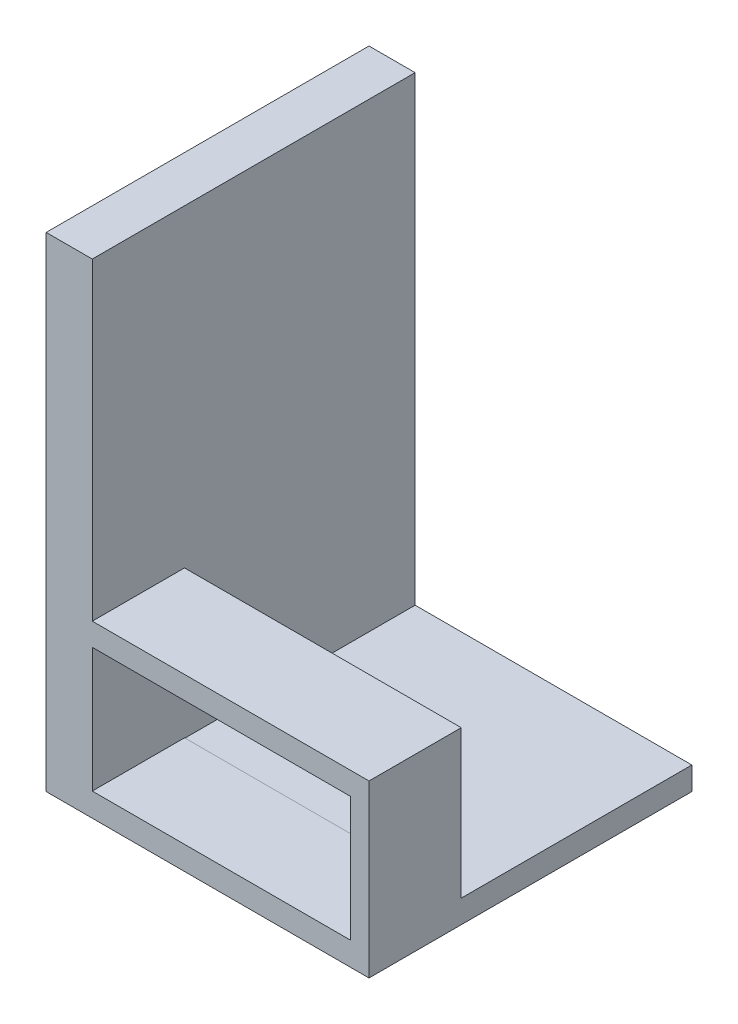
from build123d import *

# Parameters (mm, degrees)
SKETCH1_W           = 35
SKETCH1_H           = 35
BOSS_EXTRUDE1_DEPTH = 2.5
SKETCH2_W           = 5
SKETCH2_H           = 35
BOSS_EXTRUDE2_DEPTH = 50
SKETCH5_W           = 17
SKETCH5_H           = 35
CUT_EXTRUDE2_DEPTH  = 4
SKETCH6_W           = 30
SKETCH6_H           = 10
BOSS_EXTRUDE3_DEPTH = 16
SKETCH7_W           = 28
SKETCH7_H           = 13.5
CUT_EXTRUDE3_DEPTH  = 16


with BuildPart() as part:
    # Sketch1 → Boss-Extrude1 (new body)
    with BuildSketch(Plane(origin=(0, 0, 0), x_dir=(1, 0, 0), z_dir=(0, 1, 0))):
        with Locations((17.5, 17.5)):
            Rectangle(SKETCH1_W, SKETCH1_H)
    extrude(amount=BOSS_EXTRUDE1_DEPTH)

    # Sketch2 → Boss-Extrude2 (add)
    with BuildSketch(Plane(origin=(0, 2.5, 0), x_dir=(1, 0, 0), z_dir=(0, 1, 0))):
        with Locations((2.5, 17.5)):
            Rectangle(SKETCH2_W, SKETCH2_H)
    extrude(amount=BOSS_EXTRUDE2_DEPTH)

    # Sketch5 → Cut-Extrude2 (cut)
    with BuildSketch(Plane.ZY):
        with Locations((-17.553851225, 30)):
            Rectangle(SKETCH5_W, SKETCH5_H)
    extrude(amount=-CUT_EXTRUDE2_DEPTH, mode=Mode.SUBTRACT)

    # Sketch6 → Boss-Extrude3 (add)
    with BuildSketch(Plane(origin=(0, 2.5, 0), x_dir=(1, 0, 0), z_dir=(0, 1, 0))):
        with Locations((20, 5)):
            Rectangle(SKETCH6_W, SKETCH6_H)
    extrude(amount=BOSS_EXTRUDE3_DEPTH)

    # Sketch7 → Cut-Extrude3 (cut)
    with BuildSketch(Plane.XY):
        with Locations((19, 9.3)):
            Rectangle(SKETCH7_W, SKETCH7_H)
    extrude(amount=-CUT_EXTRUDE3_DEPTH, mode=Mode.SUBTRACT)


solid = part.part
